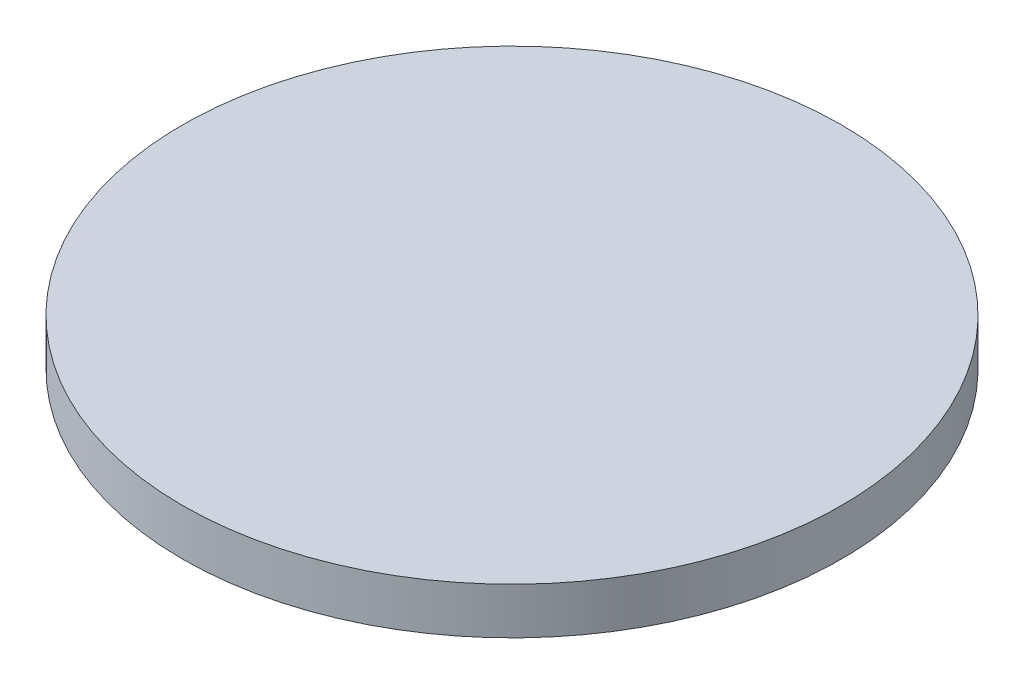
from build123d import *

# Parameters (mm, degrees)
SKETCH1_R           = 113.5
BOSS_EXTRUDE1_DEPTH = 16


with BuildPart() as part:
    # Sketch1 → Boss-Extrude1 (new body)
    with BuildSketch(Plane(origin=(0, 0, 0), x_dir=(1, 0, 0), z_dir=(0, 1, 0))):
        Circle(SKETCH1_R)
    extrude(amount=BOSS_EXTRUDE1_DEPTH)


solid = part.part
